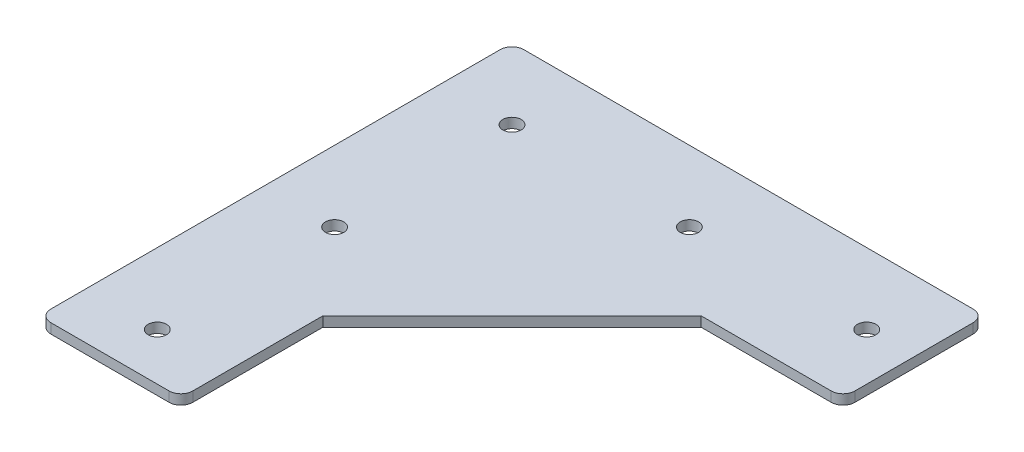
from build123d import *

# Parameters (mm, degrees)
BOSS_EXTRUDE1_DEPTH          = 2.65684
F_10_0_1935_DIAMETER_HOLE1_D = 4.9149
FILLET1_R                    = 3.175


with BuildPart() as part:
    # Sketch1 → Boss-Extrude1 (new body)
    with BuildSketch(Plane(origin=(0, 0, 0), x_dir=(1, 0, 0), z_dir=(0, 1, 0))):
        Polygon((127, 88.9), (127, 127), (88.9, 127), (0, 127), (0, 0), (38.1, 0), (38.1, 38.1), (88.9, 88.9), align=None)
    extrude(amount=BOSS_EXTRUDE1_DEPTH)

    # #10 (0.1935) Diameter Hole1 (through all)
    with Locations(Plane(origin=(0, 2.65684, 0), x_dir=(1, 0, 0), z_dir=(0, 1, 0))):
        with Locations((114.3, 107.95), (66.675, 107.95), (19.05, 107.95), (19.05, 60.325), (19.05, 12.7)):
            Hole(F_10_0_1935_DIAMETER_HOLE1_D / 2)

    # Fillet1
    fillet1_edges = [part.edges().sort_by_distance(p)[0] for p in [
        (127, 1.32842, -88.9),
        (38.1, 1.32842, 0),
        (0, 1.32842, 0),
        (0, 1.32842, -127),
        (127, 1.32842, -127),
    ]]
    fillet(fillet1_edges, radius=FILLET1_R)


solid = part.part
